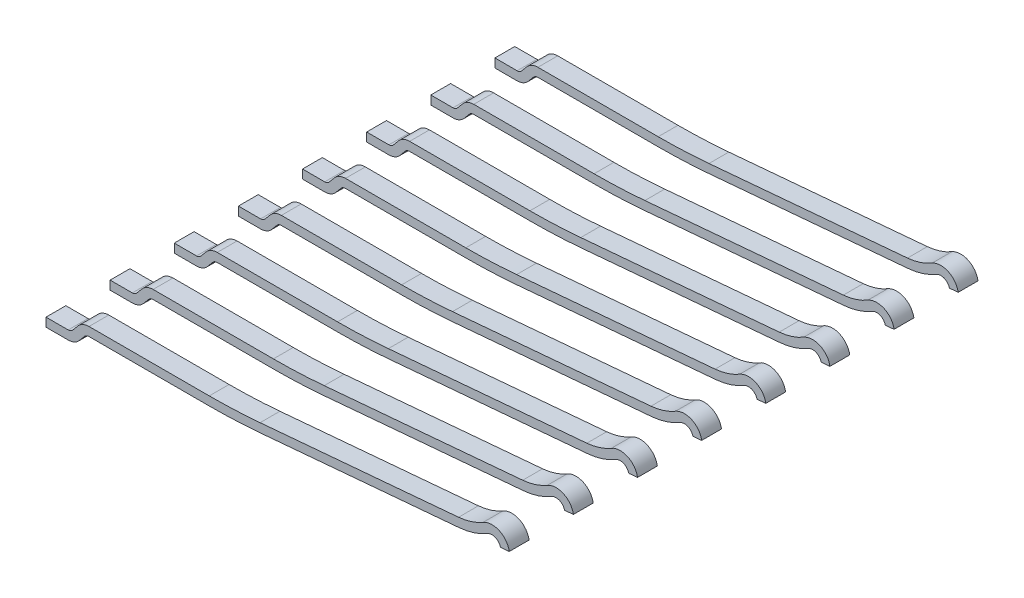
from build123d import *

# Parameters (mm, degrees)
BOSS_EXTRUDE1_DEPTH = 0.34
LPATTERN1_COUNT     = 8
LPATTERN1_PITCH     = 1.1


with BuildPart() as part:
    # Sketch1 → Boss-Extrude1 (new body)
    with BuildSketch(Plane.XY):
        with BuildLine():
            Line((-3.427355397, -0.155464216), (-3.515440437, -0.260439879))
            ThreePointArc((-3.515440437, -0.260439879), (-3.549783055, -0.286791897), (-3.592044881, -0.296161118))
            Line((-3.592044881, -0.296161118), (-3.972979553, -0.296161118))
            Line((-3.972979553, -0.296161118), (-3.972979553, -0.446161118))
            Line((-3.972979553, -0.446161118), (-3.592044881, -0.446161118))
            ThreePointArc((-3.592044881, -0.446161118), (-3.486390316, -0.422738065), (-3.400533771, -0.356858021))
            Line((-3.400533771, -0.356858021), (-3.31244873, -0.251882357))
            ThreePointArc((-3.31244873, -0.251882357), (-3.278106112, -0.22553034), (-3.235844286, -0.216161118))
            Line((-3.235844286, -0.216161118), (-1.172453715, -0.216161118))
            ThreePointArc((-1.172453715, -0.216161118), (-0.729716933, -0.206500567), (-0.287822926, -0.177537304))
            Line((-0.287822926, -0.177537304), (3.116912341, 0.120338434))
            ThreePointArc((3.116912341, 0.120338434), (3.367539913, 0.170791303), (3.600827692, 0.275368951))
            ThreePointArc((3.600827692, 0.275368951), (3.735167955, 0.284432111), (3.822655677, 0.182082975))
            Line((3.822655677, 0.182082975), (3.972979553, 0.19523461))
            ThreePointArc((3.972979553, 0.19523461), (3.803943183, 0.417989408), (3.524634937, 0.404576784))
            ThreePointArc((3.524634937, 0.404576784), (3.321775999, 0.313639699), (3.10383898, 0.269767639))
            Line((3.10383898, 0.269767639), (-0.300896287, -0.028108099))
            ThreePointArc((-0.300896287, -0.028108099), (-0.736259841, -0.056643334), (-1.172453715, -0.066161118))
            Line((-1.172453715, -0.066161118), (-3.235844286, -0.066161118))
            ThreePointArc((-3.235844286, -0.066161118), (-3.341498851, -0.089584172), (-3.427355397, -0.155464216))
        make_face()
    extrude(amount=BOSS_EXTRUDE1_DEPTH)


with BuildPart() as lpattern1_1:
    # LPattern1: pattern copy
    add(part.part.moved(Location(Vector(0, 0, -1) * (1 * LPATTERN1_PITCH))))


with BuildPart() as lpattern1_2:
    # LPattern1: pattern copy
    add(part.part.moved(Location(Vector(0, 0, -1) * (2 * LPATTERN1_PITCH))))


with BuildPart() as lpattern1_3:
    # LPattern1: pattern copy
    add(part.part.moved(Location(Vector(0, 0, -1) * (3 * LPATTERN1_PITCH))))


with BuildPart() as lpattern1_4:
    # LPattern1: pattern copy
    add(part.part.moved(Location(Vector(0, 0, -1) * (4 * LPATTERN1_PITCH))))


with BuildPart() as lpattern1_5:
    # LPattern1: pattern copy
    add(part.part.moved(Location(Vector(0, 0, -1) * (5 * LPATTERN1_PITCH))))


with BuildPart() as lpattern1_6:
    # LPattern1: pattern copy
    add(part.part.moved(Location(Vector(0, 0, -1) * (6 * LPATTERN1_PITCH))))


with BuildPart() as lpattern1_7:
    # LPattern1: pattern copy
    add(part.part.moved(Location(Vector(0, 0, -1) * (7 * LPATTERN1_PITCH))))


solid = Compound([part.part, lpattern1_1.part, lpattern1_2.part, lpattern1_3.part, lpattern1_4.part, lpattern1_5.part, lpattern1_6.part, lpattern1_7.part])
